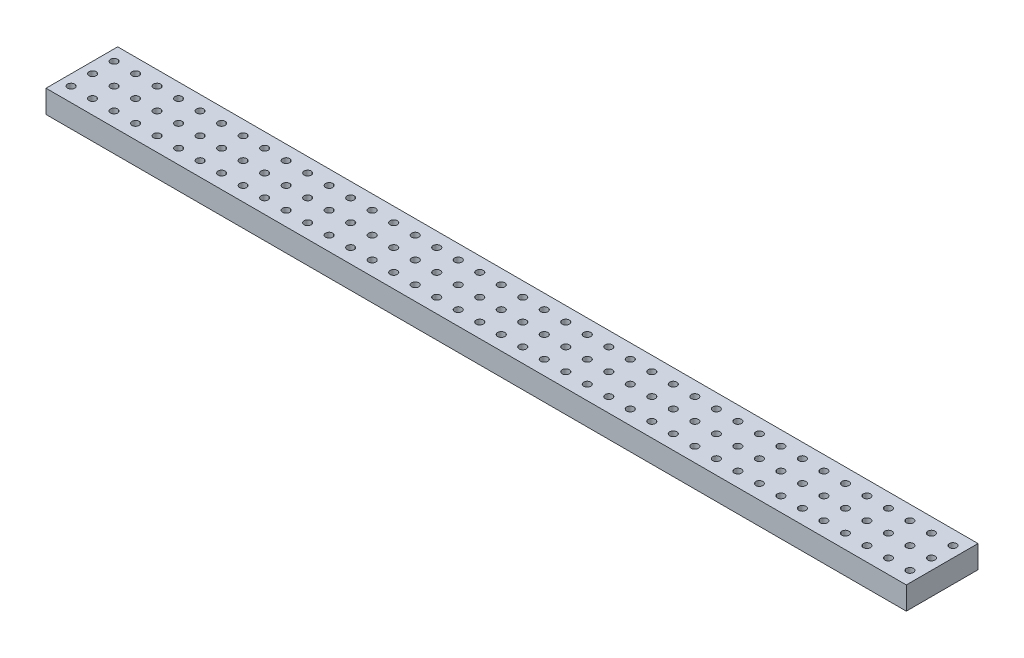
from build123d import *

# Parameters (mm, degrees)
SKETCH1_W           = 120
SKETCH1_H           = 10
SKETCH1_R           = 0.5
BOSS_EXTRUDE1_DEPTH = 3.175


with BuildPart() as part:
    # Sketch1 → Boss-Extrude1 (new body)
    with BuildSketch(Plane(origin=(0, 0, 0), x_dir=(1, 0, 0), z_dir=(0, 1, 0))):
        with Locations((60, 5)):
            Rectangle(SKETCH1_W, SKETCH1_H)
        with Locations((1.5, 8)):
            Circle(SKETCH1_R, mode=Mode.SUBTRACT)
        with Locations((1.5, 5)):
            Circle(SKETCH1_R, mode=Mode.SUBTRACT)
        with Locations((1.5, 2)):
            Circle(SKETCH1_R, mode=Mode.SUBTRACT)
        with Locations((4.5, 8)):
            Circle(SKETCH1_R, mode=Mode.SUBTRACT)
        with Locations((4.5, 5)):
            Circle(SKETCH1_R, mode=Mode.SUBTRACT)
        with Locations((4.5, 2)):
            Circle(SKETCH1_R, mode=Mode.SUBTRACT)
        with Locations((7.5, 8)):
            Circle(SKETCH1_R, mode=Mode.SUBTRACT)
        with Locations((7.5, 5)):
            Circle(SKETCH1_R, mode=Mode.SUBTRACT)
        with Locations((7.5, 2)):
            Circle(SKETCH1_R, mode=Mode.SUBTRACT)
        with Locations((10.5, 8)):
            Circle(SKETCH1_R, mode=Mode.SUBTRACT)
        with Locations((10.5, 5)):
            Circle(SKETCH1_R, mode=Mode.SUBTRACT)
        with Locations((10.5, 2)):
            Circle(SKETCH1_R, mode=Mode.SUBTRACT)
        with Locations((13.5, 8)):
            Circle(SKETCH1_R, mode=Mode.SUBTRACT)
        with Locations((13.5, 5)):
            Circle(SKETCH1_R, mode=Mode.SUBTRACT)
        with Locations((13.5, 2)):
            Circle(SKETCH1_R, mode=Mode.SUBTRACT)
        with Locations((16.5, 8)):
            Circle(SKETCH1_R, mode=Mode.SUBTRACT)
        with Locations((16.5, 5)):
            Circle(SKETCH1_R, mode=Mode.SUBTRACT)
        with Locations((16.5, 2)):
            Circle(SKETCH1_R, mode=Mode.SUBTRACT)
        with Locations((19.5, 8)):
            Circle(SKETCH1_R, mode=Mode.SUBTRACT)
        with Locations((19.5, 5)):
            Circle(SKETCH1_R, mode=Mode.SUBTRACT)
        with Locations((19.5, 2)):
            Circle(SKETCH1_R, mode=Mode.SUBTRACT)
        with Locations((22.5, 8)):
            Circle(SKETCH1_R, mode=Mode.SUBTRACT)
        with Locations((22.5, 5)):
            Circle(SKETCH1_R, mode=Mode.SUBTRACT)
        with Locations((22.5, 2)):
            Circle(SKETCH1_R, mode=Mode.SUBTRACT)
        with Locations((25.5, 8)):
            Circle(SKETCH1_R, mode=Mode.SUBTRACT)
        with Locations((25.5, 5)):
            Circle(SKETCH1_R, mode=Mode.SUBTRACT)
        with Locations((25.5, 2)):
            Circle(SKETCH1_R, mode=Mode.SUBTRACT)
        with Locations((28.5, 8)):
            Circle(SKETCH1_R, mode=Mode.SUBTRACT)
        with Locations((28.5, 5)):
            Circle(SKETCH1_R, mode=Mode.SUBTRACT)
        with Locations((28.5, 2)):
            Circle(SKETCH1_R, mode=Mode.SUBTRACT)
        with Locations((31.5, 8)):
            Circle(SKETCH1_R, mode=Mode.SUBTRACT)
        with Locations((31.5, 5)):
            Circle(SKETCH1_R, mode=Mode.SUBTRACT)
        with Locations((31.5, 2)):
            Circle(SKETCH1_R, mode=Mode.SUBTRACT)
        with Locations((34.5, 8)):
            Circle(SKETCH1_R, mode=Mode.SUBTRACT)
        with Locations((34.5, 5)):
            Circle(SKETCH1_R, mode=Mode.SUBTRACT)
        with Locations((34.5, 2)):
            Circle(SKETCH1_R, mode=Mode.SUBTRACT)
        with Locations((37.5, 8)):
            Circle(SKETCH1_R, mode=Mode.SUBTRACT)
        with Locations((37.5, 5)):
            Circle(SKETCH1_R, mode=Mode.SUBTRACT)
        with Locations((37.5, 2)):
            Circle(SKETCH1_R, mode=Mode.SUBTRACT)
        with Locations((40.5, 8)):
            Circle(SKETCH1_R, mode=Mode.SUBTRACT)
        with Locations((40.5, 5)):
            Circle(SKETCH1_R, mode=Mode.SUBTRACT)
        with Locations((40.5, 2)):
            Circle(SKETCH1_R, mode=Mode.SUBTRACT)
        with Locations((43.5, 8)):
            Circle(SKETCH1_R, mode=Mode.SUBTRACT)
        with Locations((43.5, 5)):
            Circle(SKETCH1_R, mode=Mode.SUBTRACT)
        with Locations((43.5, 2)):
            Circle(SKETCH1_R, mode=Mode.SUBTRACT)
        with Locations((46.5, 8)):
            Circle(SKETCH1_R, mode=Mode.SUBTRACT)
        with Locations((46.5, 5)):
            Circle(SKETCH1_R, mode=Mode.SUBTRACT)
        with Locations((46.5, 2)):
            Circle(SKETCH1_R, mode=Mode.SUBTRACT)
        with Locations((49.5, 8)):
            Circle(SKETCH1_R, mode=Mode.SUBTRACT)
        with Locations((49.5, 5)):
            Circle(SKETCH1_R, mode=Mode.SUBTRACT)
        with Locations((49.5, 2)):
            Circle(SKETCH1_R, mode=Mode.SUBTRACT)
        with Locations((52.5, 8)):
            Circle(SKETCH1_R, mode=Mode.SUBTRACT)
        with Locations((52.5, 5)):
            Circle(SKETCH1_R, mode=Mode.SUBTRACT)
        with Locations((52.5, 2)):
            Circle(SKETCH1_R, mode=Mode.SUBTRACT)
        with Locations((55.5, 8)):
            Circle(SKETCH1_R, mode=Mode.SUBTRACT)
        with Locations((55.5, 5)):
            Circle(SKETCH1_R, mode=Mode.SUBTRACT)
        with Locations((55.5, 2)):
            Circle(SKETCH1_R, mode=Mode.SUBTRACT)
        with Locations((58.5, 8)):
            Circle(SKETCH1_R, mode=Mode.SUBTRACT)
        with Locations((58.5, 5)):
            Circle(SKETCH1_R, mode=Mode.SUBTRACT)
        with Locations((58.5, 2)):
            Circle(SKETCH1_R, mode=Mode.SUBTRACT)
        with Locations((61.5, 8)):
            Circle(SKETCH1_R, mode=Mode.SUBTRACT)
        with Locations((61.5, 5)):
            Circle(SKETCH1_R, mode=Mode.SUBTRACT)
        with Locations((61.5, 2)):
            Circle(SKETCH1_R, mode=Mode.SUBTRACT)
        with Locations((64.5, 8)):
            Circle(SKETCH1_R, mode=Mode.SUBTRACT)
        with Locations((64.5, 5)):
            Circle(SKETCH1_R, mode=Mode.SUBTRACT)
        with Locations((64.5, 2)):
            Circle(SKETCH1_R, mode=Mode.SUBTRACT)
        with Locations((67.5, 8)):
            Circle(SKETCH1_R, mode=Mode.SUBTRACT)
        with Locations((67.5, 5)):
            Circle(SKETCH1_R, mode=Mode.SUBTRACT)
        with Locations((67.5, 2)):
            Circle(SKETCH1_R, mode=Mode.SUBTRACT)
        with Locations((70.5, 8)):
            Circle(SKETCH1_R, mode=Mode.SUBTRACT)
        with Locations((70.5, 5)):
            Circle(SKETCH1_R, mode=Mode.SUBTRACT)
        with Locations((70.5, 2)):
            Circle(SKETCH1_R, mode=Mode.SUBTRACT)
        with Locations((73.5, 8)):
            Circle(SKETCH1_R, mode=Mode.SUBTRACT)
        with Locations((73.5, 5)):
            Circle(SKETCH1_R, mode=Mode.SUBTRACT)
        with Locations((73.5, 2)):
            Circle(SKETCH1_R, mode=Mode.SUBTRACT)
        with Locations((76.5, 8)):
            Circle(SKETCH1_R, mode=Mode.SUBTRACT)
        with Locations((76.5, 5)):
            Circle(SKETCH1_R, mode=Mode.SUBTRACT)
        with Locations((76.5, 2)):
            Circle(SKETCH1_R, mode=Mode.SUBTRACT)
        with Locations((79.5, 8)):
            Circle(SKETCH1_R, mode=Mode.SUBTRACT)
        with Locations((79.5, 5)):
            Circle(SKETCH1_R, mode=Mode.SUBTRACT)
        with Locations((79.5, 2)):
            Circle(SKETCH1_R, mode=Mode.SUBTRACT)
        with Locations((82.5, 8)):
            Circle(SKETCH1_R, mode=Mode.SUBTRACT)
        with Locations((82.5, 5)):
            Circle(SKETCH1_R, mode=Mode.SUBTRACT)
        with Locations((82.5, 2)):
            Circle(SKETCH1_R, mode=Mode.SUBTRACT)
        with Locations((85.5, 8)):
            Circle(SKETCH1_R, mode=Mode.SUBTRACT)
        with Locations((85.5, 5)):
            Circle(SKETCH1_R, mode=Mode.SUBTRACT)
        with Locations((85.5, 2)):
            Circle(SKETCH1_R, mode=Mode.SUBTRACT)
        with Locations((88.5, 8)):
            Circle(SKETCH1_R, mode=Mode.SUBTRACT)
        with Locations((88.5, 5)):
            Circle(SKETCH1_R, mode=Mode.SUBTRACT)
        with Locations((88.5, 2)):
            Circle(SKETCH1_R, mode=Mode.SUBTRACT)
        with Locations((91.5, 8)):
            Circle(SKETCH1_R, mode=Mode.SUBTRACT)
        with Locations((91.5, 5)):
            Circle(SKETCH1_R, mode=Mode.SUBTRACT)
        with Locations((91.5, 2)):
            Circle(SKETCH1_R, mode=Mode.SUBTRACT)
        with Locations((94.5, 8)):
            Circle(SKETCH1_R, mode=Mode.SUBTRACT)
        with Locations((94.5, 5)):
            Circle(SKETCH1_R, mode=Mode.SUBTRACT)
        with Locations((94.5, 2)):
            Circle(SKETCH1_R, mode=Mode.SUBTRACT)
        with Locations((97.5, 8)):
            Circle(SKETCH1_R, mode=Mode.SUBTRACT)
        with Locations((97.5, 5)):
            Circle(SKETCH1_R, mode=Mode.SUBTRACT)
        with Locations((97.5, 2)):
            Circle(SKETCH1_R, mode=Mode.SUBTRACT)
        with Locations((100.5, 8)):
            Circle(SKETCH1_R, mode=Mode.SUBTRACT)
        with Locations((100.5, 5)):
            Circle(SKETCH1_R, mode=Mode.SUBTRACT)
        with Locations((100.5, 2)):
            Circle(SKETCH1_R, mode=Mode.SUBTRACT)
        with Locations((103.5, 8)):
            Circle(SKETCH1_R, mode=Mode.SUBTRACT)
        with Locations((103.5, 5)):
            Circle(SKETCH1_R, mode=Mode.SUBTRACT)
        with Locations((103.5, 2)):
            Circle(SKETCH1_R, mode=Mode.SUBTRACT)
        with Locations((106.5, 8)):
            Circle(SKETCH1_R, mode=Mode.SUBTRACT)
        with Locations((106.5, 5)):
            Circle(SKETCH1_R, mode=Mode.SUBTRACT)
        with Locations((106.5, 2)):
            Circle(SKETCH1_R, mode=Mode.SUBTRACT)
        with Locations((109.5, 8)):
            Circle(SKETCH1_R, mode=Mode.SUBTRACT)
        with Locations((109.5, 5)):
            Circle(SKETCH1_R, mode=Mode.SUBTRACT)
        with Locations((109.5, 2)):
            Circle(SKETCH1_R, mode=Mode.SUBTRACT)
        with Locations((112.5, 8)):
            Circle(SKETCH1_R, mode=Mode.SUBTRACT)
        with Locations((112.5, 5)):
            Circle(SKETCH1_R, mode=Mode.SUBTRACT)
        with Locations((112.5, 2)):
            Circle(SKETCH1_R, mode=Mode.SUBTRACT)
        with Locations((115.5, 8)):
            Circle(SKETCH1_R, mode=Mode.SUBTRACT)
        with Locations((115.5, 5)):
            Circle(SKETCH1_R, mode=Mode.SUBTRACT)
        with Locations((115.5, 2)):
            Circle(SKETCH1_R, mode=Mode.SUBTRACT)
        with Locations((118.5, 8)):
            Circle(SKETCH1_R, mode=Mode.SUBTRACT)
        with Locations((118.5, 5)):
            Circle(SKETCH1_R, mode=Mode.SUBTRACT)
        with Locations((118.5, 2)):
            Circle(SKETCH1_R, mode=Mode.SUBTRACT)
    extrude(amount=BOSS_EXTRUDE1_DEPTH)


solid = part.part
